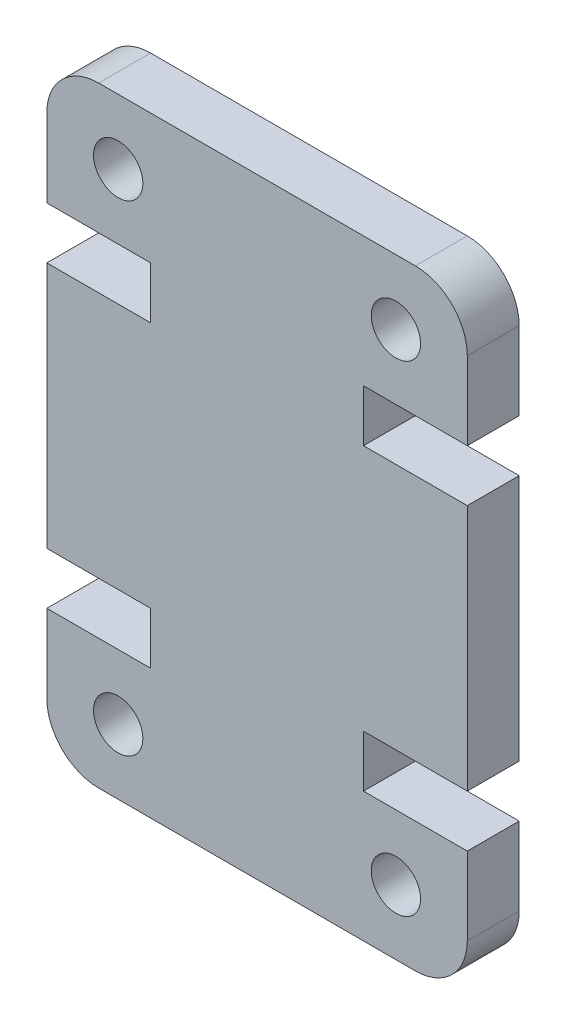
from build123d import *

# Parameters (mm, degrees)
SKETCH1_R           = 0.95
BOSS_EXTRUDE1_DEPTH = 2


with BuildPart() as part:
    # Sketch1 → Boss-Extrude1 (new body)
    with BuildSketch(Plane.XY):
        with BuildLine():
            Line((16.2, 5), (16.2, 2))
            ThreePointArc((16.2, 2), (15.614213562, 0.585786438), (14.2, 0))
            Line((14.2, 0), (2, 0))
            ThreePointArc((2, 0), (0.585786438, 0.585786438), (0, 2))
            Line((0, 2), (0, 5))
            Line((0, 5), (4, 5))
            Line((4, 5), (4, 7))
            Line((4, 7), (0, 7))
            Line((0, 7), (0, 16.525))
            Line((0, 16.525), (4, 16.525))
            Line((4, 16.525), (4, 18.525))
            Line((4, 18.525), (0, 18.525))
            Line((0, 18.525), (0, 21.525))
            ThreePointArc((0, 21.525), (0.585786438, 22.939213562), (2, 23.525))
            Line((2, 23.525), (14.2, 23.525))
            ThreePointArc((14.2, 23.525), (15.614213562, 22.939213562), (16.2, 21.525))
            Line((16.2, 21.525), (16.2, 18.525))
            Line((16.2, 18.525), (12.2, 18.525))
            Line((12.2, 18.525), (12.2, 16.525))
            Line((12.2, 16.525), (16.2, 16.525))
            Line((16.2, 16.525), (16.2, 7))
            Line((16.2, 7), (12.2, 7))
            Line((12.2, 7), (12.2, 5))
            Line((12.2, 5), (16.2, 5))
        make_face()
        with Locations((13.45, 2.5)):
            Circle(SKETCH1_R, mode=Mode.SUBTRACT)
        with Locations((2.75, 21.025)):
            Circle(SKETCH1_R, mode=Mode.SUBTRACT)
        with Locations((13.45, 21.025)):
            Circle(SKETCH1_R, mode=Mode.SUBTRACT)
        with Locations((2.75, 2.5)):
            Circle(SKETCH1_R, mode=Mode.SUBTRACT)
    extrude(amount=BOSS_EXTRUDE1_DEPTH)


solid = part.part
